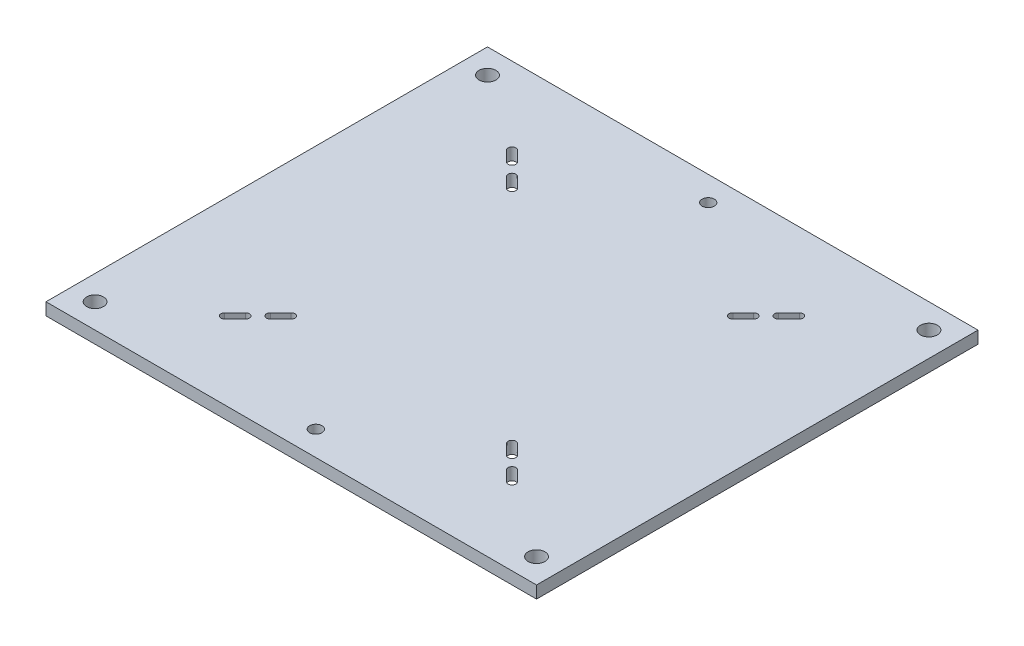
from build123d import *

# Parameters (mm, degrees)
SKETCH1_W                            = 254
SKETCH1_H                            = 228.6
BASE_PLATE_DEPTH                     = 6.35
SLOTS_DEPTH                          = 7.35
FEET_CONNECTION_HOLE_D               = 8.7376
HOLE_FOR_10_BLIND_FASTENERS_B_BS_1_D = 6.35


with BuildPart() as part:
    # Sketch1 → base plate (new body)
    with BuildSketch(Plane(origin=(0, 0, 0), x_dir=(1, 0, 0), z_dir=(0, 1, 0))):
        with Locations((127, -114.3)):
            Rectangle(SKETCH1_W, SKETCH1_H)
    extrude(amount=-BASE_PLATE_DEPTH)

    # Sketch3 → slots (cut, through all)
    with BuildSketch(Plane(origin=(0, 0, 0), x_dir=(1, 0, 0), z_dir=(0, 1, 0))):
        with BuildLine():
            ThreePointArc((59.421325374, -43.892898159), (59.421325374, -46.721325374), (56.592898159, -46.721325374))
            Line((56.592898159, -46.721325374), (51.204744487, -41.333171702))
            ThreePointArc((51.204744487, -41.333171702), (51.204744487, -38.504744487), (54.033171702, -38.504744487))
            Line((54.033171702, -38.504744487), (59.421325374, -43.892898159))
        make_face()
        with BuildLine():
            Line((199.966828298, -38.504744487), (194.578674626, -43.892898159))
            ThreePointArc((194.578674626, -43.892898159), (194.578674626, -46.721325374), (197.407101841, -46.721325374))
            Line((197.407101841, -46.721325374), (202.795255513, -41.333171702))
            ThreePointArc((202.795255513, -41.333171702), (202.795255513, -38.504744487), (199.966828298, -38.504744487))
        make_face()
        with BuildLine():
            Line((185.598418504, -58.530008711), (190.986572177, -53.141855038))
            ThreePointArc((190.986572177, -53.141855038), (190.986572177, -50.313427823), (188.158144962, -50.313427823))
            Line((188.158144962, -50.313427823), (182.769991289, -55.701581496))
            ThreePointArc((182.769991289, -55.701581496), (182.769991289, -58.530008711), (185.598418504, -58.530008711))
        make_face()
        with BuildLine():
            ThreePointArc((190.986572177, -175.458144962), (190.986572177, -178.286572177), (188.158144962, -178.286572177))
            Line((188.158144962, -178.286572177), (182.769991289, -172.898418504))
            ThreePointArc((182.769991289, -172.898418504), (182.769991289, -170.069991289), (185.598418504, -170.069991289))
            Line((185.598418504, -170.069991289), (190.986572177, -175.458144962))
        make_face()
        with BuildLine():
            ThreePointArc((194.578674626, -184.707101841), (194.578674626, -181.878674626), (197.407101841, -181.878674626))
            Line((197.407101841, -181.878674626), (202.795255513, -187.266828298))
            ThreePointArc((202.795255513, -187.266828298), (202.795255513, -190.095255513), (199.966828298, -190.095255513))
            Line((199.966828298, -190.095255513), (194.578674626, -184.707101841))
        make_face()
        with BuildLine():
            Line((54.033171702, -190.095255513), (59.421325374, -184.707101841))
            ThreePointArc((59.421325374, -184.707101841), (59.421325374, -181.878674626), (56.592898159, -181.878674626))
            Line((56.592898159, -181.878674626), (51.204744487, -187.266828298))
            ThreePointArc((51.204744487, -187.266828298), (51.204744487, -190.095255513), (54.033171702, -190.095255513))
        make_face()
        with BuildLine():
            Line((68.401581496, -170.069991289), (63.013427823, -175.458144962))
            ThreePointArc((63.013427823, -175.458144962), (63.013427823, -178.286572177), (65.841855038, -178.286572177))
            Line((65.841855038, -178.286572177), (71.230008711, -172.898418504))
            ThreePointArc((71.230008711, -172.898418504), (71.230008711, -170.069991289), (68.401581496, -170.069991289))
        make_face()
        with BuildLine():
            Line((68.401581496, -58.530008711), (63.013427823, -53.141855038))
            ThreePointArc((63.013427823, -53.141855038), (63.013427823, -50.313427823), (65.841855038, -50.313427823))
            Line((65.841855038, -50.313427823), (71.230008711, -55.701581496))
            ThreePointArc((71.230008711, -55.701581496), (71.230008711, -58.530008711), (68.401581496, -58.530008711))
        make_face()
    extrude(amount=-SLOTS_DEPTH, mode=Mode.SUBTRACT)

    # Feet connection hole (through all)
    with Locations(Plane(origin=(0, 0, 0), x_dir=(1, 0, 0), z_dir=(0, 1, 0))):
        with Locations((12.7, -215.9), (241.3, -12.7), (12.7, -12.7), (241.3, -215.9)):
            Hole(FEET_CONNECTION_HOLE_D / 2)

    # Hole for #10 Blind Fasteners (B,BS)1 (through all)
    with Locations(Plane(origin=(0, 0, 0), x_dir=(1, 0, 0), z_dir=(0, 1, 0))):
        with Locations((127, -215.9), (127, -12.7)):
            Hole(HOLE_FOR_10_BLIND_FASTENERS_B_BS_1_D / 2)


solid = part.part
